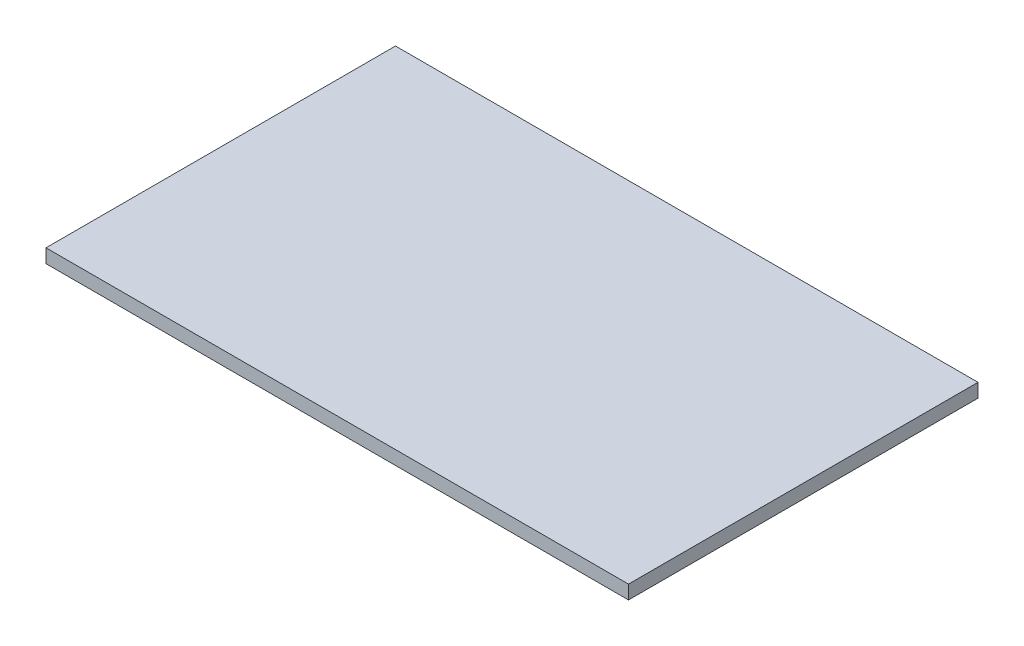
from build123d import *

# Parameters (mm, degrees)
SKETCH1_W           = 254
SKETCH1_H           = 152.4
BOSS_EXTRUDE1_DEPTH = 6


with BuildPart() as part:
    # Sketch1 → Boss-Extrude1 (new body)
    with BuildSketch(Plane(origin=(0, 0, 0), x_dir=(1, 0, 0), z_dir=(0, 1, 0))):
        Rectangle(SKETCH1_W, SKETCH1_H)
    extrude(amount=BOSS_EXTRUDE1_DEPTH)


solid = part.part
